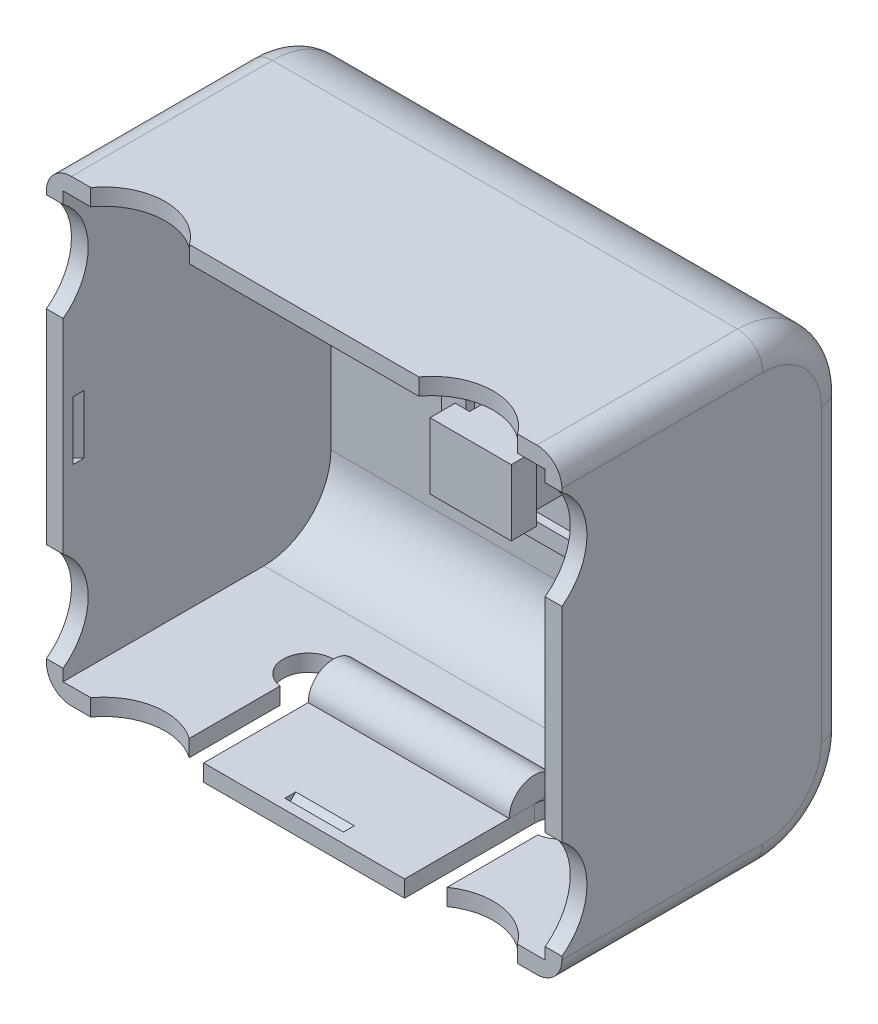
from build123d import *

# Parameters (mm, degrees)
EXTRUDE_1_DEPTH     = 61.6
SHELL_1_T           = -2
FILLET_2_R          = 3
CUT_EXTRUDE_1_REACH = 36
SKETCH_3_W          = 4.6
SKETCH_3_H          = 7.4
SKETCH_4_W          = 4.6
SKETCH_4_H          = 7.4
EXTRUDE_2_DEPTH     = 3.7
SKETCH_5_W          = 2.95
SKETCH_5_H          = 7.9
SKETCH_5_W_2        = 25.755
SKETCH_5_H_2        = 2
EXTRUDE_3_DEPTH     = 1
EXTRUDE_4_DEPTH     = 7.897587
CUT_EXTRUDE_START   = -61.6
CUT_EXTRUDE_3_DEPTH = 61.6
CUT_EXTRUDE_START_2 = -54.8
CUT_EXTRUDE_4_DEPTH = 54.8
CUT_EXTRUDE_5_DEPTH = 3.5
CUT_EXTRUDE_6_DEPTH = 3.5
CUT_EXTRUDE_START_3 = -2
CUT_EXTRUDE_7_DEPTH = 2
EXTRUDE_5_DEPTH     = 24.01


with BuildPart() as part:
    # ｽｹｯﾁ2 → ﾎﾞｽ - 押し出し1 (new body)
    with BuildSketch(Plane(origin=(0, 0, 0), x_dir=(0, 0, -1), z_dir=(1, 0, 0))):
        with BuildLine():
            Line((0, 0), (24, 0))
            ThreePointArc((24, 0), (31.071067812, 2.928932188), (34, 10))
            Line((34, 10), (34, 44.8))
            ThreePointArc((34, 44.8), (31.071067812, 51.871067812), (24, 54.8))
            Line((24, 54.8), (0, 54.8))
            Line((0, 54.8), (0, 0))
        make_face()
    extrude(amount=EXTRUDE_1_DEPTH)

    # ｼｪﾙ1
    shell_1_openings = [part.faces().sort_by_distance(p)[0] for p in [
        (30.8, 27.4, 0),
    ]]
    offset(amount=SHELL_1_T, openings=shell_1_openings, kind=Kind.INTERSECTION)

    # ﾌｨﾚｯﾄ2
    fillet_2_edges = [part.edges().sort_by_distance(p)[0] for p in [
        (61.6, 2.928932188, -31.071067812),
        (61.6, 27.4, -34),
        (61.6, 51.871067812, -31.071067812),
        (61.6, 54.8, -12),
        (0, 54.8, -12),
        (0, 51.871067812, -31.071067812),
        (0, 27.4, -34),
        (61.6, 0, -12),
        (0, 2.928932188, -31.071067812),
        (0, 0, -12),
    ]]
    fillet(fillet_2_edges, radius=FILLET_2_R)

    # ｽｹｯﾁ3 → ｶｯﾄ - 押し出し1 (cut, up to next)
    with BuildSketch(Plane(origin=(0, 0, -34), x_dir=(-1, 0, 0), z_dir=(0, 0, -1)), mode=Mode.PRIVATE) as cut_extrude_1_sk1:
        with Locations((-37.2975, 27.4)):
            Rectangle(SKETCH_3_W, SKETCH_3_H)
    cut_extrude_1_tool1 = extrude(cut_extrude_1_sk1.sketch, amount=-CUT_EXTRUDE_1_REACH, mode=Mode.PRIVATE) & part.part
    add(cut_extrude_1_tool1.solids().sort_by_distance((37.2975, 27.4, -34))[0], mode=Mode.SUBTRACT)
    # ｽｹｯﾁ3 → ｶｯﾄ - 押し出し1 (cut, up to next)
    with BuildSketch(Plane(origin=(0, 0, -34), x_dir=(-1, 0, 0), z_dir=(0, 0, -1)), mode=Mode.PRIVATE) as cut_extrude_1_sk2:
        with Locations((-24.3025, 27.4)):
            Rectangle(SKETCH_3_W, SKETCH_3_H)
    cut_extrude_1_tool2 = extrude(cut_extrude_1_sk2.sketch, amount=-CUT_EXTRUDE_1_REACH, mode=Mode.PRIVATE) & part.part
    add(cut_extrude_1_tool2.solids().sort_by_distance((24.3025, 27.4, -34))[0], mode=Mode.SUBTRACT)

    # ｽｹｯﾁ4 → ﾎﾞｽ - 押し出し2 (add)
    with BuildSketch(Plane.XY.offset(-34)):
        Polygon((17.9225, 15.575), (30.6725, 15.575), (43.6775, 15.575), (43.6775, 39.225), (30.6725, 39.225), (17.9225, 39.225), align=None)
        with Locations((24.3025, 27.4)):
            Rectangle(SKETCH_4_W, SKETCH_4_H, mode=Mode.SUBTRACT)
        with Locations((37.2975, 27.4)):
            Rectangle(SKETCH_4_W, SKETCH_4_H, mode=Mode.SUBTRACT)
    extrude(amount=EXTRUDE_2_DEPTH)

    # ｽｹｯﾁ5 → ﾎﾞｽ - 押し出し3 (add)
    with BuildSketch(Plane.XY.offset(-30.3)):
        with Locations((19.3975, 27.4)):
            Rectangle(SKETCH_5_W, SKETCH_5_H)
        with Locations((42.2025, 27.4)):
            Rectangle(SKETCH_5_W, SKETCH_5_H)
        with Locations((30.8, 38.225)):
            Rectangle(SKETCH_5_W_2, SKETCH_5_H_2)
        with Locations((30.8, 16.575)):
            Rectangle(SKETCH_5_W_2, SKETCH_5_H_2)
    extrude(amount=EXTRUDE_3_DEPTH)

    # ｽｹｯﾁ6 → ﾎﾞｽ - 押し出し4 (add)
    with BuildSketch(Plane(origin=(-6.518280687, 23.45241299, -44.223812227), x_dir=(1, 0, 0), z_dir=(0, 1, 0))):
        Polygon((34.190780687, -13.923812227), (40.445780687, -13.923812227), (40.445780687, -21.323812227), (42.170780687, -21.323812227), (42.170780687, -24.323812227), (32.465780687, -24.323812227), (32.465780687, -21.323812227), (34.190780687, -21.323812227), align=None)
    extrude(amount=EXTRUDE_4_DEPTH)

    # ｽｹｯﾁ8 → ｶｯﾄ - 押し出し3 (cut)
    with BuildSketch(Plane.ZY.offset(CUT_EXTRUDE_START)):
        with BuildLine():
            Line((0, 51.399152482), (0, 39.600847518))
            ThreePointArc((0, 39.600847518), (-3, 45.5), (0, 51.399152482))
        make_face()
        with BuildLine():
            Line((0, 15.199152482), (0, 3.400847518))
            ThreePointArc((0, 3.400847518), (-3, 9.3), (0, 15.199152482))
        make_face()
    extrude(amount=CUT_EXTRUDE_3_DEPTH, mode=Mode.SUBTRACT)

    # ｽｹｯﾁ9 → ｶｯﾄ - 押し出し4 (cut)
    with BuildSketch(Plane.XZ.offset(CUT_EXTRUDE_START_2)):
        with BuildLine():
            Line((56.299152482, 0), (44.500847518, 0))
            ThreePointArc((44.500847518, 0), (50.4, -3), (56.299152482, 0))
        make_face()
        with BuildLine():
            Line((17.099152482, 0), (5.300847518, 0))
            ThreePointArc((5.300847518, 0), (11.2, -3), (17.099152482, 0))
        make_face()
    extrude(amount=CUT_EXTRUDE_4_DEPTH, mode=Mode.SUBTRACT)

    # ｽｹｯﾁ11 → ｶｯﾄ - 押し出し5 (cut, symmetric)
    with BuildSketch(Plane(origin=(0, 27.4, 0), x_dir=(-1, 0, 0), z_dir=(0, -1, 0))):
        Polygon((-59.6, 1.176601917), (-59.6, 2.476687437), (-60.288664164, 1.788023273), (-60.288664164, 1.176601917), align=None)
        Polygon((-1.311335836, 1.176601917), (-2, 1.176601917), (-2, 2.476687437), (-1.311335836, 1.788023273), align=None)
    extrude(amount=CUT_EXTRUDE_5_DEPTH, both=True, mode=Mode.SUBTRACT)

    # ｽｹｯﾁ12 → ｶｯﾄ - 押し出し6 (cut, symmetric)
    with BuildSketch(Plane(origin=(30.8, 0, 0), x_dir=(0, 0, -1), z_dir=(1, 0, 0))):
        Polygon((2.501421356, 2), (1.201335836, 2), (1.201335836, 1.311335836), (1.812757192, 1.311335836), align=None)
        Polygon((1.812757192, 53.488664164), (2.501421356, 52.8), (1.201335836, 52.8), (1.201335836, 53.488664164), align=None)
    extrude(amount=CUT_EXTRUDE_6_DEPTH, both=True, mode=Mode.SUBTRACT)

    # ｽｹｯﾁ13 → ｶｯﾄ - 押し出し7 (cut)
    with BuildSketch(Plane.XZ.offset(CUT_EXTRUDE_START_3)):
        with BuildLine():
            Line((15.396028325, 0), (15.396028325, -12.526786251))
            ThreePointArc((15.396028325, -12.526786251), (13.821186559, -17.758317958), (18.796028325, -15.5))
            Line((18.796028325, -15.5), (18.796028325, 0))
            Line((18.796028325, 0), (15.396028325, 0))
        make_face()
        with BuildLine():
            Line((46.203971675, 0), (42.803971675, 0))
            Line((42.803971675, 0), (42.803971675, -15.5))
            ThreePointArc((42.803971675, -15.5), (47.778813441, -17.758317958), (46.203971675, -12.526786251))
            Line((46.203971675, -12.526786251), (46.203971675, 0))
        make_face()
    extrude(amount=CUT_EXTRUDE_7_DEPTH, mode=Mode.SUBTRACT)

    # ｽｹｯﾁ14 → ﾎﾞｽ - 押し出し5 (add)
    with BuildSketch(Plane.ZY.offset(-18.796028325)):
        with BuildLine():
            Line((-12.5, 2), (-18.5, 2))
            ThreePointArc((-18.5, 2), (-15.5, 5), (-12.5, 2))
        make_face()
    extrude(amount=-EXTRUDE_5_DEPTH)


solid = part.part
